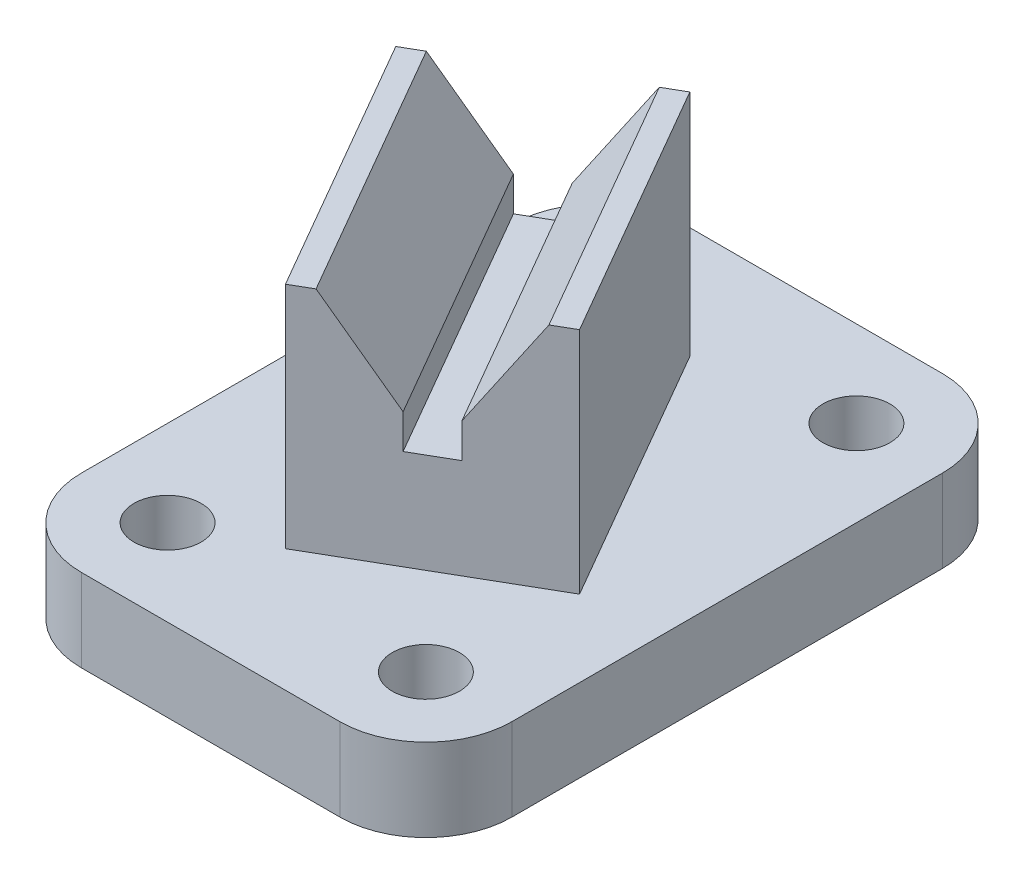
from build123d import *

# Parameters (mm, degrees)
SKETCH1_W            = 63.5
SKETCH1_H            = 88.9
EXTRUDE1_DEPTH       = 12.192
SKETCH2_R            = 4.953
CUT_EXTRUDE1_DEPTH   = 13.192
LPATTERN1_COUNT      = 2
LPATTERN1_PITCH      = 63.5
LPATTERN1_COUNT_DIR2 = 2
LPATTERN1_PITCH_DIR2 = 38.1
FILLET1_R            = 12.7
EXTRUDE2_DEPTH       = 33.782
CUT_EXTRUDE3_DEPTH   = 74.683081323


with BuildPart() as part:
    # Sketch1 → Extrude1 (new body)
    with BuildSketch(Plane(origin=(0, 0, 0), x_dir=(1, 0, 0), z_dir=(0, 1, 0))):
        with Locations((2.085074627, -2.677425373)):
            Rectangle(SKETCH1_W, SKETCH1_H)
    extrude(amount=-EXTRUDE1_DEPTH)

    # Sketch2 → Cut-Extrude1 (cut, through all)
    with BuildSketch(Plane(origin=(0, 0, 0), x_dir=(-1, 0, 0), z_dir=(0, 1, 0))):
        with Locations((-21.135074627, 34.427425373)):
            Circle(SKETCH2_R)
    cut_extrude1 = extrude(amount=-CUT_EXTRUDE1_DEPTH, mode=Mode.SUBTRACT)

    # LPattern1: Cut-Extrude1 2 × 2
    with Locations(*[(-j * LPATTERN1_PITCH_DIR2, 0, -i * LPATTERN1_PITCH) for i in range(LPATTERN1_COUNT) for j in range(LPATTERN1_COUNT_DIR2) if (i, j) != (0, 0)]):
        add(cut_extrude1, mode=Mode.SUBTRACT)

    # Fillet1
    fillet1_edges = [part.edges().sort_by_distance(p)[0] for p in [
        (-29.664925373, -6.096, -41.772574627),
        (33.835074627, -6.096, -41.772574627),
        (33.835074627, -6.096, 47.127425373),
        (-29.664925373, -6.096, 47.127425373),
    ]]
    fillet(fillet1_edges, radius=FILLET1_R)

    # Sketch4 → Extrude2 (add)
    with BuildSketch(Plane(origin=(0, 0, 0), x_dir=(-1, 0, 0), z_dir=(0, 1, 0))):
        Polygon((-0.31333595, -25.325077129), (-22.53833595, 13.169752069), (4.95797062, 29.044752069), (27.18297062, -9.450077129), align=None)
    extrude(amount=EXTRUDE2_DEPTH)

    # Sketch5 → Cut-Extrude3 (cut, through all)
    with BuildSketch(Plane(origin=(11.337253914, 0, 19.636699798), x_dir=(0.866025404, 0, -0.5), z_dir=(0.5, 0, 0.866025404))):
        Polygon((-110.61611964, 175.14986028), (-15.514104542, 33.782), (-6.116104542, 19.812), (-6.116104542, 14.732), (0.233895458, 14.732), (0.233895458, 19.812), (9.631895458, 33.782), (104.733910555, 175.14986028), (104.733910555, 515.909395413), (-110.61611964, 515.909395413), align=None)
    extrude(amount=-CUT_EXTRUDE3_DEPTH, mode=Mode.SUBTRACT)


solid = part.part
